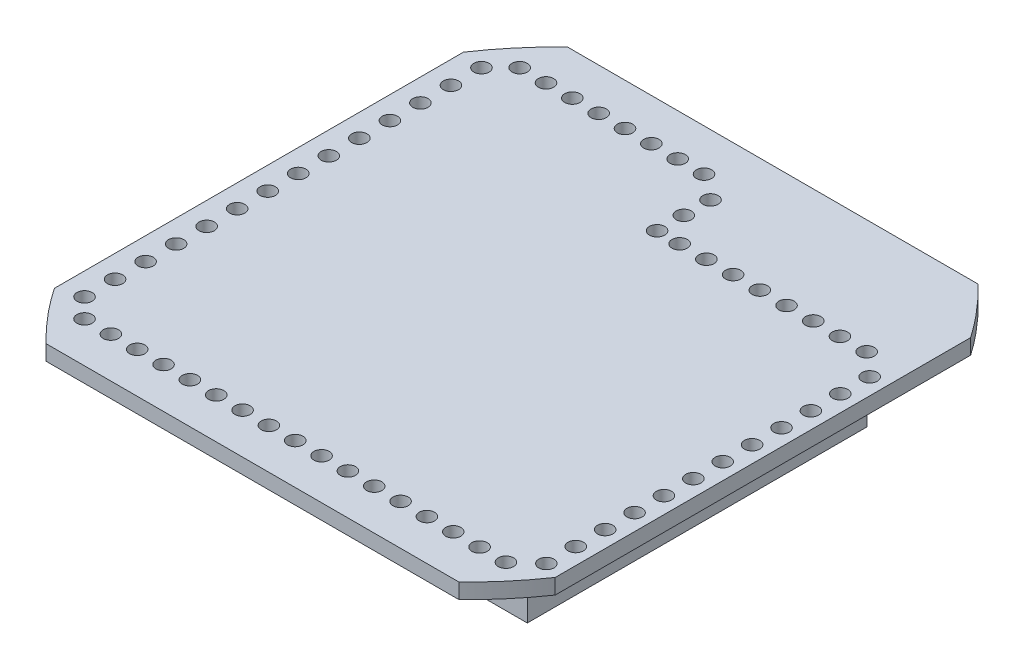
from build123d import *

# Parameters (mm, degrees)
SKETCH1_W           = 111
SKETCH1_H           = 85
BOSS_EXTRUDE2_DEPTH = 10
BOSS_EXTRUDE3_DEPTH = 10
SKETCH6_W           = 164
SKETCH6_H           = 158
BOSS_EXTRUDE4_DEPTH = 4
SKETCH9_R           = 2
CUT_EXTRUDE2_DEPTH  = 4
SKETCH10_W          = 186.872555015
SKETCH10_H          = 195.411118235
SKETCH10_RX         = 90
SKETCH10_RY         = 82
CUT_EXTRUDE3_DEPTH  = 4
SKETCH12_W          = 135.891970627
SKETCH12_H          = 13.567997068
CUT_EXTRUDE4_DEPTH  = 4
SKETCH13_W          = 129.508722698
SKETCH13_H          = 20.729944062
CUT_EXTRUDE5_DEPTH  = 4
SKETCH15_W          = 21.747653555
SKETCH15_H          = 111.151158821
SKETCH15_W_2        = 52.162007652
SKETCH15_H_2        = 113.873917653
CUT_EXTRUDE6_DEPTH  = 4


with BuildPart() as part:
    # Sketch1 → Boss-Extrude2 (new body)
    with BuildSketch(Plane(origin=(0, 0, 0), x_dir=(1, 0, 0), z_dir=(0, 1, 0))):
        Polygon((0, 89), (0, 0), (115, 0), (115, 89), (112, 89), (64, 89), (62, 89), align=None)
        with Locations((57.5, 44.5)):
            Rectangle(SKETCH1_W, SKETCH1_H, mode=Mode.SUBTRACT)
    extrude(amount=BOSS_EXTRUDE2_DEPTH)

    # Sketch5 → Boss-Extrude3 (add)
    with BuildSketch(Plane(origin=(0, 10, 0), x_dir=(1, 0, 0), z_dir=(0, 1, 0))):
        Polygon((54, 89), (54, 108), (0, 108), (0, 89), (2, 89), (2, 106), (52, 106), (52, 89), align=None)
    extrude(amount=-BOSS_EXTRUDE3_DEPTH)

    # Sketch6 → Boss-Extrude4 (add)
    with BuildSketch(Plane(origin=(0, 10, 0), x_dir=(1, 0, 0), z_dir=(0, 1, 0))):
        with Locations((57, 54)):
            Rectangle(SKETCH6_W, SKETCH6_H)
    extrude(amount=BOSS_EXTRUDE4_DEPTH)

    # Sketch9 → Cut-Extrude2 (cut)
    with BuildSketch(Plane.XZ.offset(-10)):
        with Locations((2, 3)):
            Circle(SKETCH9_R)
        with Locations((8.9, 3)):
            Circle(SKETCH9_R)
        with Locations((15.8, 3)):
            Circle(SKETCH9_R)
        with Locations((22.7, 3)):
            Circle(SKETCH9_R)
        with Locations((29.6, 3)):
            Circle(SKETCH9_R)
        with Locations((36.5, 3)):
            Circle(SKETCH9_R)
        with Locations((43.4, 3)):
            Circle(SKETCH9_R)
        with Locations((50.3, 3)):
            Circle(SKETCH9_R)
        with Locations((57.2, 3)):
            Circle(SKETCH9_R)
        with Locations((64.1, 3)):
            Circle(SKETCH9_R)
        with Locations((71, 3)):
            Circle(SKETCH9_R)
        with Locations((77.9, 3)):
            Circle(SKETCH9_R)
        with Locations((-3, -2)):
            Circle(SKETCH9_R)
        with Locations((-3, -10)):
            Circle(SKETCH9_R)
        with Locations((-3, -18)):
            Circle(SKETCH9_R)
        with Locations((-3, -26)):
            Circle(SKETCH9_R)
        with Locations((-3, -34)):
            Circle(SKETCH9_R)
        with Locations((-3, -42)):
            Circle(SKETCH9_R)
        with Locations((-3, -50)):
            Circle(SKETCH9_R)
        with Locations((-3, -58)):
            Circle(SKETCH9_R)
        with Locations((-3, -66)):
            Circle(SKETCH9_R)
        with Locations((-3, -74)):
            Circle(SKETCH9_R)
        with Locations((-3, -82)):
            Circle(SKETCH9_R)
        with Locations((-3, -90)):
            Circle(SKETCH9_R)
        with Locations((-3, -98)):
            Circle(SKETCH9_R)
        with Locations((-3, -106)):
            Circle(SKETCH9_R)
        with Locations((118, -2)):
            Circle(SKETCH9_R)
        with Locations((118, -9.7)):
            Circle(SKETCH9_R)
        with Locations((118, -17.4)):
            Circle(SKETCH9_R)
        with Locations((118, -25.1)):
            Circle(SKETCH9_R)
        with Locations((118, -32.8)):
            Circle(SKETCH9_R)
        with Locations((118, -40.5)):
            Circle(SKETCH9_R)
        with Locations((118, -48.2)):
            Circle(SKETCH9_R)
        with Locations((118, -55.9)):
            Circle(SKETCH9_R)
        with Locations((118, -63.6)):
            Circle(SKETCH9_R)
        with Locations((118, -71.3)):
            Circle(SKETCH9_R)
        with Locations((118, -79)):
            Circle(SKETCH9_R)
        with Locations((118, -86.7)):
            Circle(SKETCH9_R)
        with Locations((2, -111)):
            Circle(SKETCH9_R)
        with Locations((8.9, -111)):
            Circle(SKETCH9_R)
        with Locations((15.8, -111)):
            Circle(SKETCH9_R)
        with Locations((22.7, -111)):
            Circle(SKETCH9_R)
        with Locations((29.6, -111)):
            Circle(SKETCH9_R)
        with Locations((36.5, -111)):
            Circle(SKETCH9_R)
        with Locations((43.4, -111)):
            Circle(SKETCH9_R)
        with Locations((50.3, -111)):
            Circle(SKETCH9_R)
        with Locations((57, -106)):
            Circle(SKETCH9_R)
        with Locations((57, -99)):
            Circle(SKETCH9_R)
        with Locations((57, -92)):
            Circle(SKETCH9_R)
        with Locations((111.916693377, -92)):
            Circle(SKETCH9_R)
        with Locations((104.916693377, -92)):
            Circle(SKETCH9_R)
        with Locations((97.916693377, -92)):
            Circle(SKETCH9_R)
        with Locations((90.916693377, -92)):
            Circle(SKETCH9_R)
        with Locations((83.916693377, -92)):
            Circle(SKETCH9_R)
        with Locations((76.916693377, -92)):
            Circle(SKETCH9_R)
        with Locations((69.916693377, -92)):
            Circle(SKETCH9_R)
        with Locations((62.916693377, -92)):
            Circle(SKETCH9_R)
        with Locations((84.8, 3)):
            Circle(SKETCH9_R)
        with Locations((91.7, 3)):
            Circle(SKETCH9_R)
        with Locations((98.6, 3)):
            Circle(SKETCH9_R)
        with Locations((105.5, 3)):
            Circle(SKETCH9_R)
        with Locations((112.4, 3)):
            Circle(SKETCH9_R)
    extrude(amount=-CUT_EXTRUDE2_DEPTH, mode=Mode.SUBTRACT)

    # Sketch10 → Cut-Extrude3 (cut)
    with BuildSketch(Plane(origin=(0, 10, 0), x_dir=(-1, 0, 0), z_dir=(0, -1, 0))):
        with Locations((-60.171466338, 51.926348933)):
            Rectangle(SKETCH10_W, SKETCH10_H)
        with Locations(Location((-57, 54), (0, 0, -88.194857017))):
            Ellipse(SKETCH10_RX, SKETCH10_RY, mode=Mode.SUBTRACT)
    extrude(amount=-CUT_EXTRUDE3_DEPTH, mode=Mode.SUBTRACT)

    # Sketch12 → Cut-Extrude4 (cut)
    with BuildSketch(Plane.XZ.offset(-10)):
        with Locations((56.258000161, 20.433355362)):
            Rectangle(SKETCH12_W, SKETCH12_H)
    extrude(amount=-CUT_EXTRUDE4_DEPTH, mode=Mode.SUBTRACT)

    # Sketch13 → Cut-Extrude5 (cut)
    with BuildSketch(Plane(origin=(0, 10, 0), x_dir=(-1, 0, 0), z_dir=(0, -1, 0))):
        with Locations((-61.487926034, 132.323810054)):
            Rectangle(SKETCH13_W, SKETCH13_H)
    extrude(amount=-CUT_EXTRUDE5_DEPTH, mode=Mode.SUBTRACT)

    # Sketch15 → Cut-Extrude6 (cut)
    with BuildSketch(Plane(origin=(0, 10, 0), x_dir=(-1, 0, 0), z_dir=(0, -1, 0))):
        with Locations((19.765115189, 55.575579411)):
            Rectangle(SKETCH15_W, SKETCH15_H)
        with Locations((-148.394552911, 56.936958827)):
            Rectangle(SKETCH15_W_2, SKETCH15_H_2)
    extrude(amount=-CUT_EXTRUDE6_DEPTH, mode=Mode.SUBTRACT)


solid = part.part
